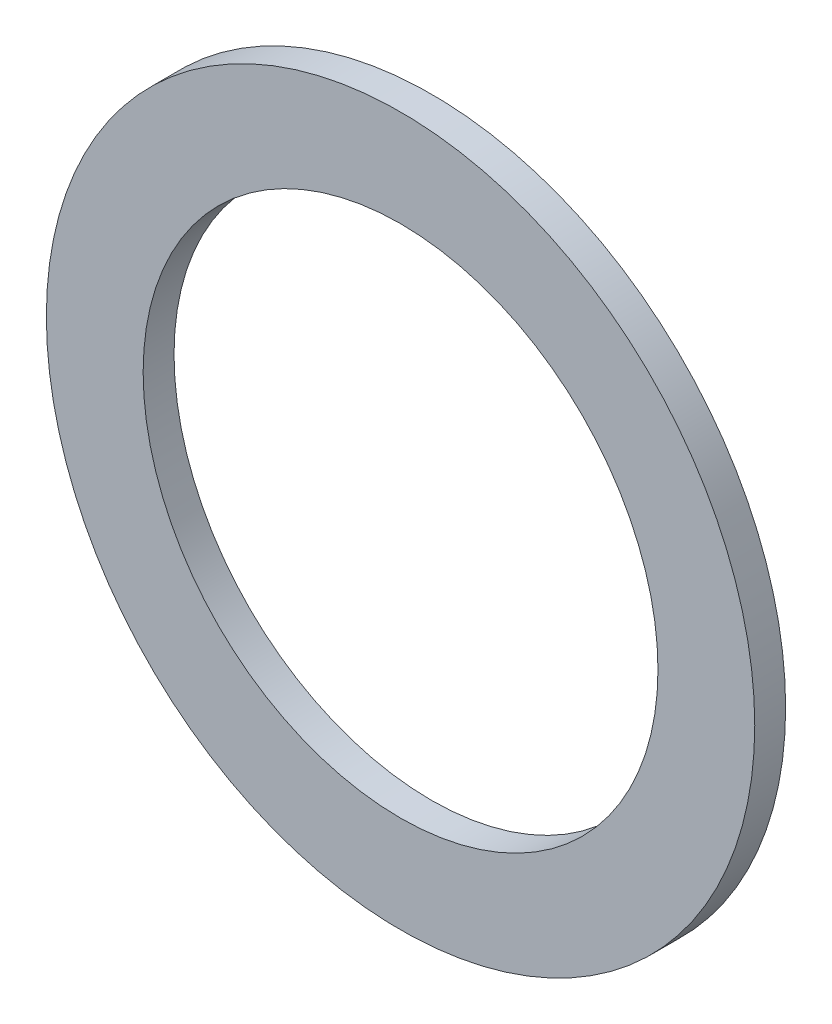
from build123d import *

# Parameters (mm, degrees)
SKETCH1_R           = 8.7376
SKETCH1_R_2         = 6.35
BOSS_EXTRUDE1_DEPTH = 0.762


with BuildPart() as part:
    # Sketch1 → Boss-Extrude1 (new body)
    with BuildSketch(Plane.XY):
        Circle(SKETCH1_R)
        Circle(SKETCH1_R_2, mode=Mode.SUBTRACT)
    extrude(amount=BOSS_EXTRUDE1_DEPTH)


solid = part.part
